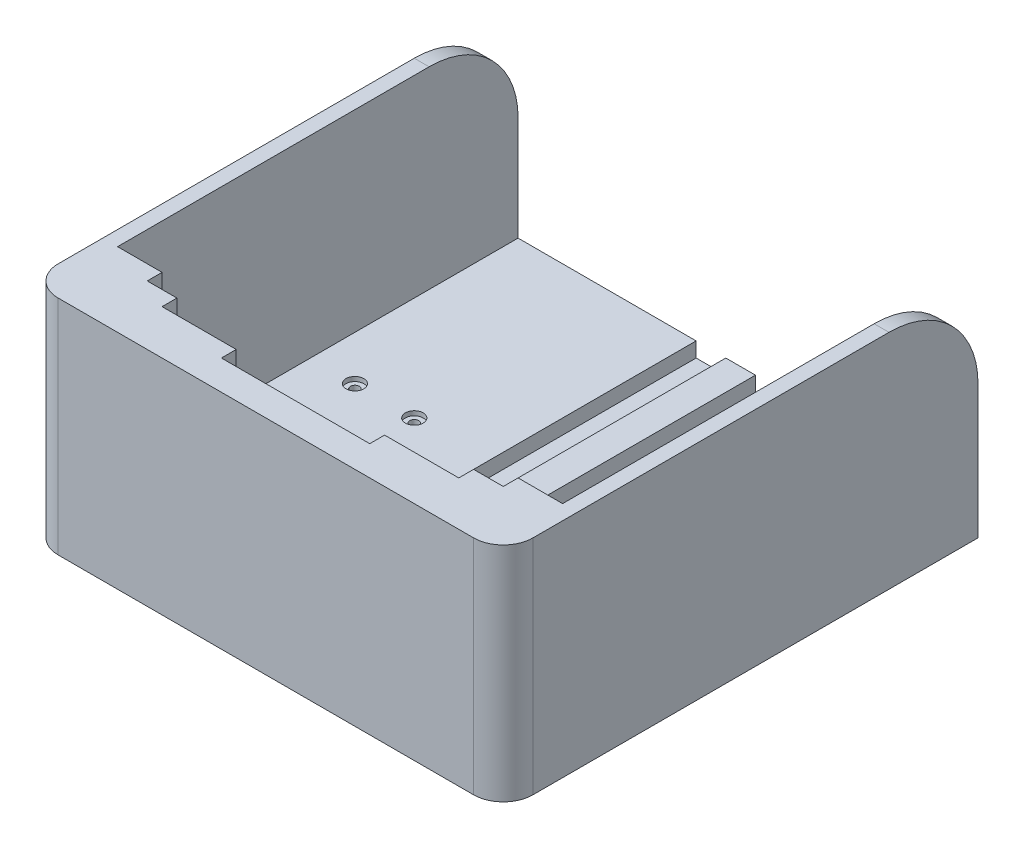
from build123d import *

# Parameters (mm, degrees)
SKETCH1_W           = 160
SKETCH1_H           = 160
BOSS_EXTRUDE1_DEPTH = 75
SKETCH2_W           = 150
SKETCH2_H           = 150
CUT_EXTRUDE1_DEPTH  = 65
SKETCH3_W           = 15
SKETCH3_H           = 65
BOSS_EXTRUDE2_DEPTH = 15
SKETCH4_W           = 10
SKETCH4_H           = 65
BOSS_EXTRUDE3_DEPTH = 10
FILLET1_R           = 10
SKETCH11_W          = 25
SKETCH11_H          = 65
BOSS_EXTRUDE4_DEPTH = 5
FILLET2_R           = 30
SKETCH15_R          = 1.5
CUT_EXTRUDE2_DEPTH  = 10
SKETCH17_R          = 3
CUT_EXTRUDE3_DEPTH  = 1.5
SKETCH18_W          = 10
SKETCH18_H          = 145
CUT_EXTRUDE6_DEPTH  = 5


with BuildPart() as part:
    # Sketch1 → Boss-Extrude1 (new body)
    with BuildSketch(Plane(origin=(0, 0, 0), x_dir=(1, 0, 0), z_dir=(0, 1, 0))):
        Rectangle(SKETCH1_W, SKETCH1_H)
    extrude(amount=BOSS_EXTRUDE1_DEPTH)

    # Sketch2 → Cut-Extrude1 (cut)
    with BuildSketch(Plane(origin=(0, 75, 0), x_dir=(1, 0, 0), z_dir=(0, 1, 0))):
        with Locations((0, 5)):
            Rectangle(SKETCH2_W, SKETCH2_H)
    extrude(amount=-CUT_EXTRUDE1_DEPTH, mode=Mode.SUBTRACT)

    # Sketch3 → Boss-Extrude2 (add)
    with BuildSketch(Plane(origin=(0, 0, 70), x_dir=(-1, 0, 0), z_dir=(0, 0, -1))):
        with Locations((-67.5, 42.5)):
            Rectangle(SKETCH3_W, SKETCH3_H)
        with Locations((67.5, 42.5)):
            Rectangle(SKETCH3_W, SKETCH3_H)
    extrude(amount=BOSS_EXTRUDE2_DEPTH)

    # Sketch4 → Boss-Extrude3 (add)
    with BuildSketch(Plane(origin=(0, 0, 70), x_dir=(-1, 0, 0), z_dir=(0, 0, -1))):
        with Locations((-55, 42.5)):
            Rectangle(SKETCH4_W, SKETCH4_H)
        with Locations((55, 42.5)):
            Rectangle(SKETCH4_W, SKETCH4_H)
    extrude(amount=BOSS_EXTRUDE3_DEPTH)

    # Fillet1
    fillet1_edges = [part.edges().sort_by_distance(p)[0] for p in [
        (80, 37.5, 80),
        (-80, 37.5, 80),
    ]]
    fillet(fillet1_edges, radius=FILLET1_R)

    # Sketch11 → Boss-Extrude4 (add)
    with BuildSketch(Plane(origin=(0, 0, 70), x_dir=(-1, 0, 0), z_dir=(0, 0, -1))):
        with Locations((-37.5, 42.5)):
            Rectangle(SKETCH11_W, SKETCH11_H)
        with Locations((37.5, 42.5)):
            Rectangle(SKETCH11_W, SKETCH11_H)
    extrude(amount=BOSS_EXTRUDE4_DEPTH)

    # Fillet2
    fillet2_edges = [part.edges().sort_by_distance(p)[0] for p in [
        (-77.5, 75, -80),
        (77.5, 75, -80),
    ]]
    fillet(fillet2_edges, radius=FILLET2_R)

    # Sketch15 → Cut-Extrude2 (cut)
    with BuildSketch(Plane.XZ):
        with Locations((-60, 10)):
            Circle(SKETCH15_R)
        with Locations((-40, 10)):
            Circle(SKETCH15_R)
        with Locations((40, 10)):
            Circle(SKETCH15_R)
        with Locations((60, 10)):
            Circle(SKETCH15_R)
        with Locations((60, -10)):
            Circle(SKETCH15_R)
        with Locations((40, -10)):
            Circle(SKETCH15_R)
        with Locations((-40, -10)):
            Circle(SKETCH15_R)
        with Locations((-60, -10)):
            Circle(SKETCH15_R)
    extrude(amount=-CUT_EXTRUDE2_DEPTH, mode=Mode.SUBTRACT)

    # Sketch17 → Cut-Extrude3 (cut)
    with BuildSketch(Plane(origin=(0, 10, 0), x_dir=(1, 0, 0), z_dir=(0, 1, 0))):
        with Locations((-60, 10)):
            Circle(SKETCH17_R)
        with Locations((-40, 10)):
            Circle(SKETCH17_R)
        with Locations((-40, -10)):
            Circle(SKETCH17_R)
        with Locations((-60, -10)):
            Circle(SKETCH17_R)
        with Locations((40, -10)):
            Circle(SKETCH17_R)
        with Locations((60, -10)):
            Circle(SKETCH17_R)
        with Locations((40, 10)):
            Circle(SKETCH17_R)
        with Locations((60, 10)):
            Circle(SKETCH17_R)
    extrude(amount=-CUT_EXTRUDE3_DEPTH, mode=Mode.SUBTRACT)

    # Sketch18 → Cut-Extrude6 (cut)
    with BuildSketch(Plane(origin=(0, 10, 0), x_dir=(1, 0, 0), z_dir=(0, 1, 0))):
        with Locations((10, 7.5)):
            Rectangle(SKETCH18_W, SKETCH18_H)
        with Locations((-10, 7.5)):
            Rectangle(SKETCH18_W, SKETCH18_H)
    extrude(amount=-CUT_EXTRUDE6_DEPTH, mode=Mode.SUBTRACT)


solid = part.part
